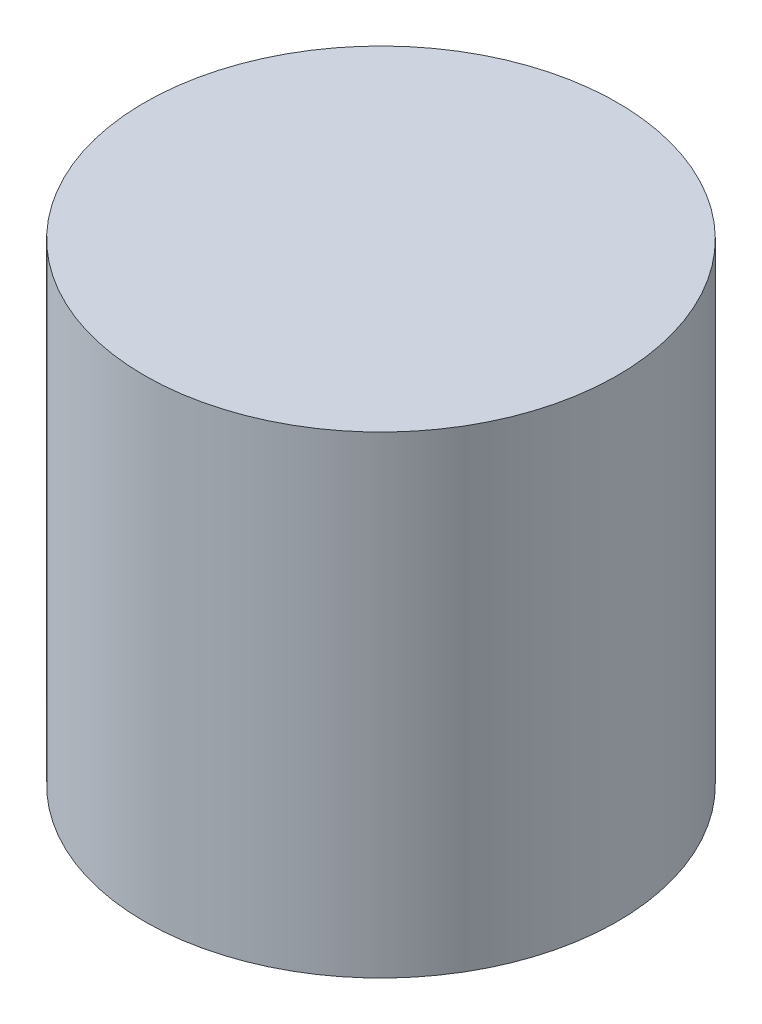
from build123d import *

# Parameters (mm, degrees)
SKETCH2_R           = 9.525
BOSS_EXTRUDE1_DEPTH = 19.05


with BuildPart() as part:
    # Sketch2 → Boss-Extrude1 (new body)
    with BuildSketch(Plane(origin=(0, 0, 0), x_dir=(1, 0, 0), z_dir=(0, 1, 0))):
        Circle(SKETCH2_R)
    extrude(amount=BOSS_EXTRUDE1_DEPTH)


solid = part.part
